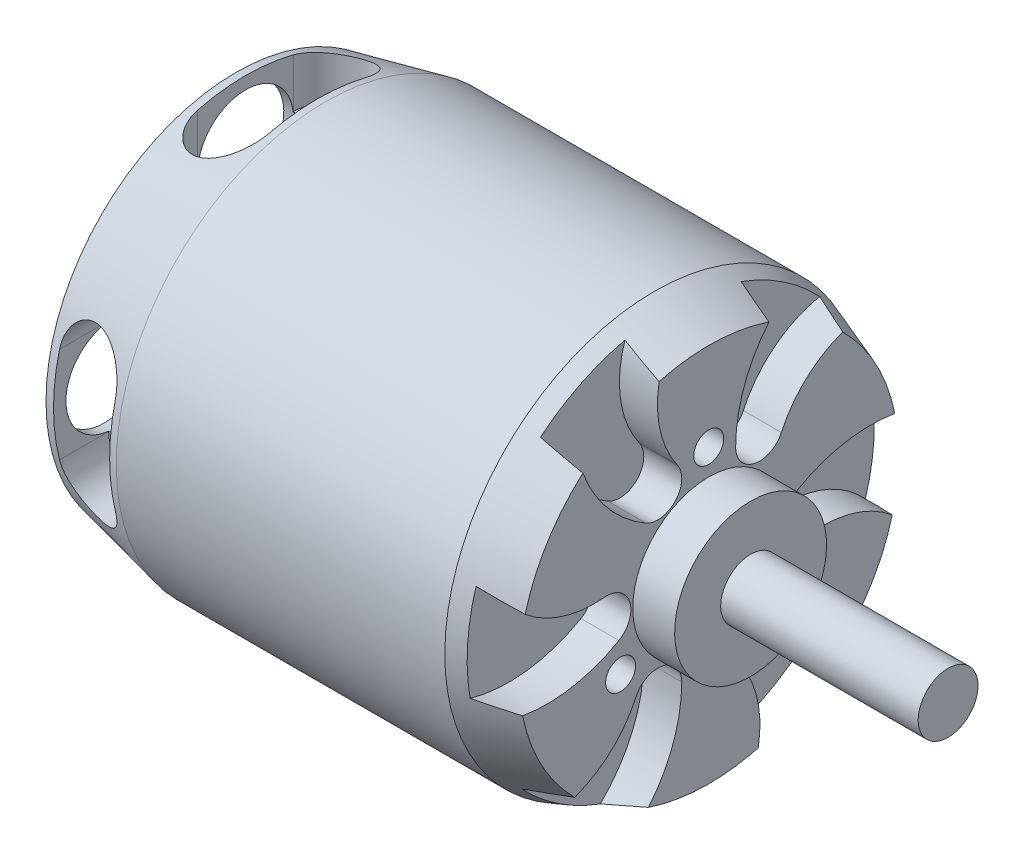
from build123d import *

# Parameters (mm, degrees)
SKETCH2_R          = 1.25
CUT_EXTRUDE1_DEPTH = 6.35
SKETCH3_R          = 1.5
CUT_EXTRUDE2_DEPTH = 6.35
CUT_EXTRUDE5_START = 17.78
CUT_EXTRUDE5_DEPTH = 6.35
SKETCH4_R          = 4
CUT_EXTRUDE3_DEPTH = 6.8
CIRPATTERN1_COUNT  = 4
CUT_EXTRUDE4_DEPTH = 3.175
CIRPATTERN2_COUNT  = 6


with BuildPart() as part:
    # Sketch1 → Revolve1 (revolve)
    with BuildSketch(Plane.XY):
        Polygon((0, 0), (0, 15.865968489), (7.5, 17.5), (34.951150155, 17.5), (39.5, 15.865968489), (39.5, 6.346727069), (43, 6.346727069), (43, 2.5), (59.5, 2.5), (59.5, 0), align=None)
    revolve(axis=Axis((59.5, 0, 0), (-1, 0, 0)))

    # Sketch2 → Cut-Extrude1 (cut)
    with BuildSketch(Plane(origin=(39.5, 0, 0), x_dir=(0, 0, -1), z_dir=(1, 0, 0))):
        with Locations((0, 8.5)):
            Circle(SKETCH2_R)
        with Locations((7.361215932, -4.25)):
            Circle(SKETCH2_R)
        with Locations((-7.361215932, -4.25)):
            Circle(SKETCH2_R)
    extrude(amount=-CUT_EXTRUDE1_DEPTH, mode=Mode.SUBTRACT)

    # Sketch3 → Cut-Extrude2 (cut)
    with BuildSketch(Plane.ZY):
        with Locations((-8.838834765, 8.838834765)):
            Circle(SKETCH3_R)
        with Locations((8.838834765, -8.838834765)):
            Circle(SKETCH3_R)
        with Locations((6.717514421, 6.717514421)):
            Circle(SKETCH3_R)
        with Locations((-6.717514421, -6.717514421)):
            Circle(SKETCH3_R)
    extrude(amount=-CUT_EXTRUDE2_DEPTH, mode=Mode.SUBTRACT)

    # Sketch6 → Cut-Extrude5 (cut)
    with BuildSketch(Plane(origin=(0, 0, 0), x_dir=(1, 0, 0), z_dir=(0, 1, 0)).offset(CUT_EXTRUDE5_START)):
        with BuildLine():
            Line((6.8, 4), (6.8, -4))
            ThreePointArc((6.8, -4), (3.8, -7), (0.8, -4))
            Line((0.8, -4), (0.8, 4))
            ThreePointArc((0.8, 4), (3.8, 7), (6.8, 4))
        make_face()
    cut_extrude5 = extrude(amount=-CUT_EXTRUDE5_DEPTH, mode=Mode.SUBTRACT)

    # Sketch4 → Cut-Extrude3 (cut)
    with BuildSketch(Plane.ZY):
        with Locations((0, 11)):
            Circle(SKETCH4_R)
    cut_extrude3 = extrude(amount=-CUT_EXTRUDE3_DEPTH, mode=Mode.SUBTRACT)

    # CirPattern1: Cut-Extrude5, Cut-Extrude3 ×4 about axis
    cirpattern1_axis = Axis((0, 0, 0), (1, 0, 0))
    for i in range(1, CIRPATTERN1_COUNT):
        add(cut_extrude5.rotate(cirpattern1_axis, i * 360 / CIRPATTERN1_COUNT), mode=Mode.SUBTRACT)
        add(cut_extrude3.rotate(cirpattern1_axis, i * 360 / CIRPATTERN1_COUNT), mode=Mode.SUBTRACT)

    # Sketch5 → Cut-Extrude4 (cut)
    with BuildSketch(Plane(origin=(39.5, 0, 0), x_dir=(0, 0, -1), z_dir=(1, 0, 0))):
        with BuildLine():
            ThreePointArc((2.25, 7.361215932), (3.823598567, 5.40719909), (6.068181818, 6.528020351))
            ThreePointArc((6.068181818, 6.528020351), (18.421673948, 10.753421518), (21.995966692, -1.803935458))
            ThreePointArc((21.995966692, -1.803935458), (19.302148043, 18.245874868), (2.25, 7.361215932))
        make_face()
    cut_extrude4 = extrude(amount=-CUT_EXTRUDE4_DEPTH, mode=Mode.SUBTRACT)

    # CirPattern2: Cut-Extrude4 ×6 about axis
    cirpattern2_axis = Axis((0, 0, 0), (1, 0, 0))
    for i in range(1, CIRPATTERN2_COUNT):
        add(cut_extrude4.rotate(cirpattern2_axis, i * 360 / CIRPATTERN2_COUNT), mode=Mode.SUBTRACT)


solid = part.part
